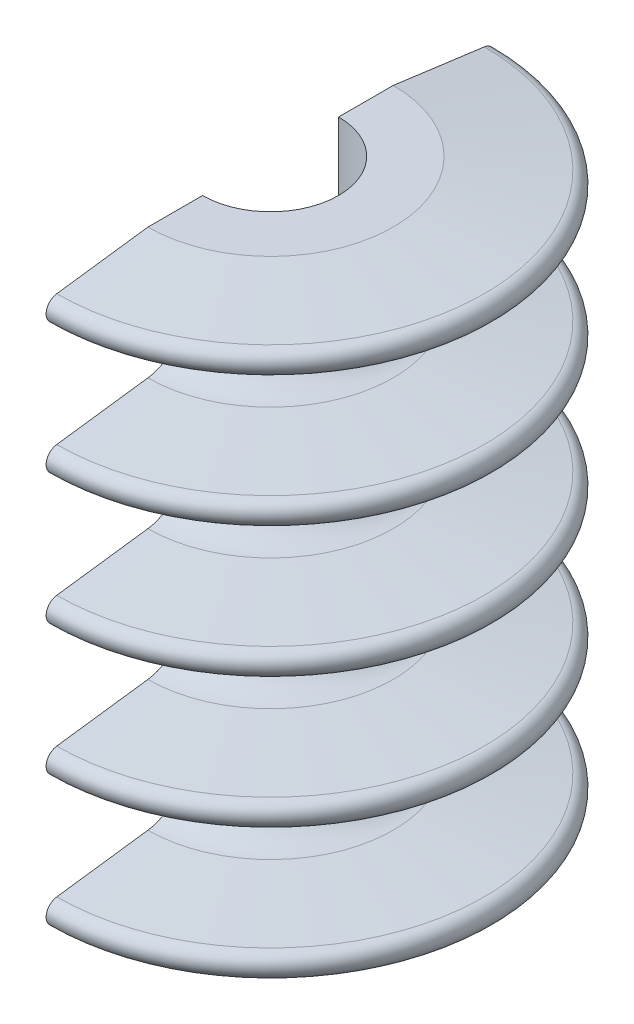
from build123d import *

# Parameters (mm, degrees)
CUT_EXTRUDE1_REACH = 109.549
SKETCH3_W          = 63.794129447
SKETCH3_H          = 110.135148007
SKETCH4_R          = 1.7
CUT_EXTRUDE2_DEPTH = 71.283409658
CUT_EXTRUDE3_DEPTH = 3.8


with BuildPart() as part:
    # Sketch2 → Revolve1 (revolve)
    with BuildSketch(Plane.XY):
        with BuildLine():
            Line((-20.2, -39), (-35.2, -41))
            ThreePointArc((-35.2, -41), (-36.951032793, -43), (-35.2, -45))
            Line((-35.2, -45), (-20.2, -47))
            Line((-20.2, -47), (-11.2, -47))
            Line((-11.2, -47), (-11.2, 47))
            Line((-11.2, 47), (-20.2, 47))
            Line((-20.2, 47), (-35.2, 45))
            ThreePointArc((-35.2, 45), (-36.951032793, 43), (-35.2, 41))
            Line((-35.2, 41), (-20.2, 39))
            ThreePointArc((-20.2, 39), (-14.290264322, 32.25), (-20.2, 25.5))
            Line((-20.2, 25.5), (-35.2, 23.5))
            ThreePointArc((-35.2, 23.5), (-36.951032793, 21.5), (-35.2, 19.5))
            Line((-35.2, 19.5), (-20.2, 17.5))
            ThreePointArc((-20.2, 17.5), (-14.290264322, 10.75), (-20.2, 4))
            Line((-20.2, 4), (-35.2, 2))
            ThreePointArc((-35.2, 2), (-36.951032793, 0), (-35.2, -2))
            Line((-35.2, -2), (-20.2, -4))
            ThreePointArc((-20.2, -4), (-14.290264322, -10.75), (-20.2, -17.5))
            Line((-20.2, -17.5), (-35.2, -19.5))
            ThreePointArc((-35.2, -19.5), (-36.951032793, -21.5), (-35.2, -23.5))
            Line((-35.2, -23.5), (-20.2, -25.5))
            ThreePointArc((-20.2, -25.5), (-14.290264322, -32.25), (-20.2, -39))
        make_face()
    revolve(axis=Axis((0, 47, 0), (0, -1, 0)))

    # Cut-Extrude1: up to this face of the body (flat: up to its plane)
    cut_extrude1_end = Plane(part.part.faces().sort_by_distance((11.771342279, 47, 0))[0])
    # Sketch3 → Cut-Extrude1 (cut, up to the picked face)
    with BuildSketch(Plane.XZ.offset(47), mode=Mode.PRIVATE) as cut_extrude1_sk1:
        with Locations((-31.897064724, -0.067055114)):
            Rectangle(SKETCH3_W, SKETCH3_H)
    cut_extrude1_tool1 = split(extrude(cut_extrude1_sk1.sketch, amount=-CUT_EXTRUDE1_REACH, mode=Mode.PRIVATE), bisect_by=cut_extrude1_end, keep=Keep.BOTH, mode=Mode.PRIVATE)
    add(cut_extrude1_tool1.solids().sort_by(Axis((-31.897065, -47, -0.067055), (0, 1, 0)))[0], mode=Mode.SUBTRACT)

    # Sketch4 → Cut-Extrude2 (cut, through all)
    with BuildSketch(Plane(origin=(0, 0, 0), x_dir=(0, 0, -1), z_dir=(1, 0, 0))):
        with Locations(Location((0, -32.25, 0), (0, 0, 180))):
            Circle(SKETCH4_R)
        with Locations(Location((0, 32.25, 0), (0, 0, 180))):
            Circle(SKETCH4_R)
    extrude(amount=CUT_EXTRUDE2_DEPTH, mode=Mode.SUBTRACT)

    # Sketch5 → Cut-Extrude3 (cut)
    with BuildSketch(Plane(origin=(17, 0, 0), x_dir=(0, 0, -1), z_dir=(1, 0, 0))):
        Polygon((-2.95, -30.546816706), (-2.95, -33.953183294), (0, -35.656366588), (2.95, -33.953183294), (2.95, -30.546816706), (0, -28.843633412), align=None)
        Polygon((-2.95, 30.546816706), (0, 28.843633412), (2.95, 30.546816706), (2.95, 33.953183294), (0, 35.656366588), (-2.95, 33.953183294), align=None)
    extrude(amount=-CUT_EXTRUDE3_DEPTH, mode=Mode.SUBTRACT)


solid = part.part
